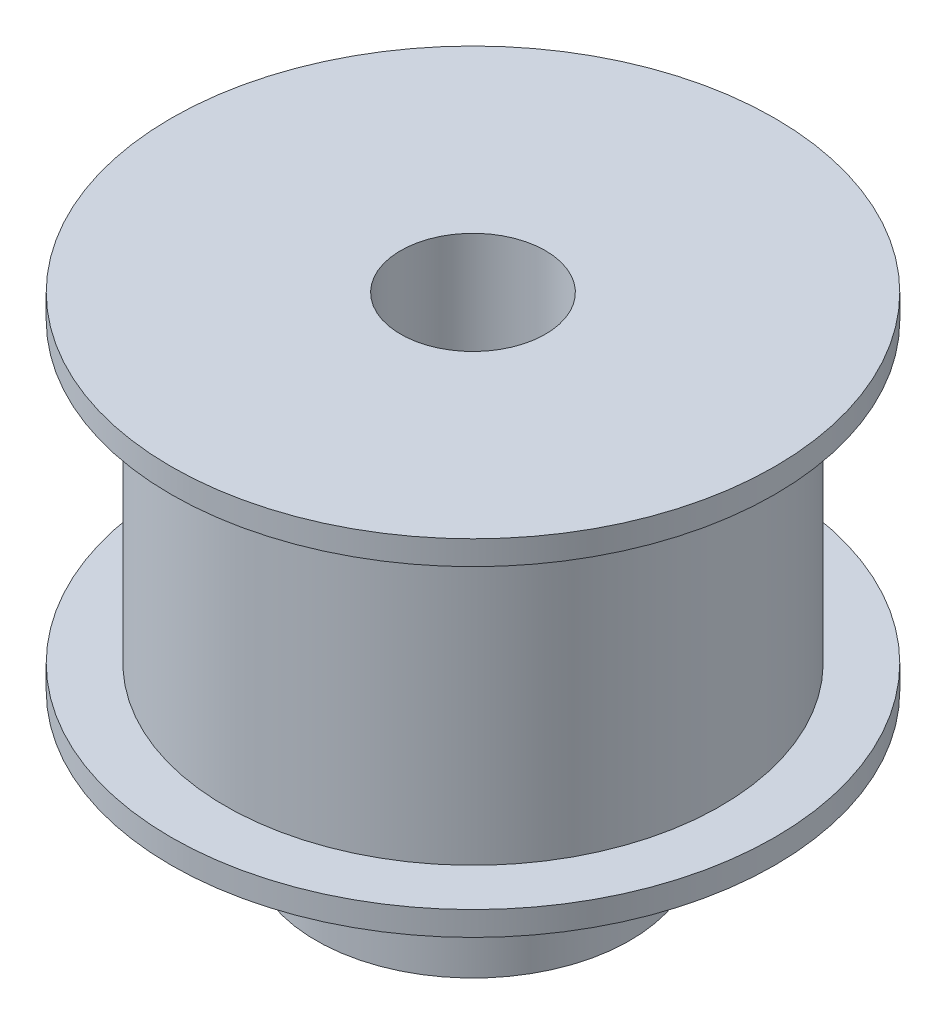
from build123d import *

# Parameters (mm, degrees)
SKETCH3_R          = 3
CUT_EXTRUDE1_DEPTH = 21


with BuildPart() as part:
    # Sketch2 → Revolve1 (revolve)
    with BuildSketch(Plane.XY, mode=Mode.PRIVATE) as revolve1_sk:
        Polygon((6.5, 0), (0, 0), (0, 20), (12.5, 20), (12.5, 19), (10.255, 19), (10.255, 6.7), (12.5, 6.7), (12.5, 5.7), (6.5, 5.7), align=None)
    revolve(revolve1_sk.sketch.rotate(Axis((0, 0, 0), (0, 1, 0)), 90), axis=Axis((0, 0, 0), (0, 1, 0)))  # turned: the seam where the file's is

    # Sketch3 → Cut-Extrude1 (cut, through all)
    with BuildSketch(Plane.XZ):
        with Locations(Location((0, 0, 0), (0, 0, 270))):  # turned: the seam where the file's is
            Circle(SKETCH3_R)
    extrude(amount=-CUT_EXTRUDE1_DEPTH, mode=Mode.SUBTRACT)


solid = part.part
